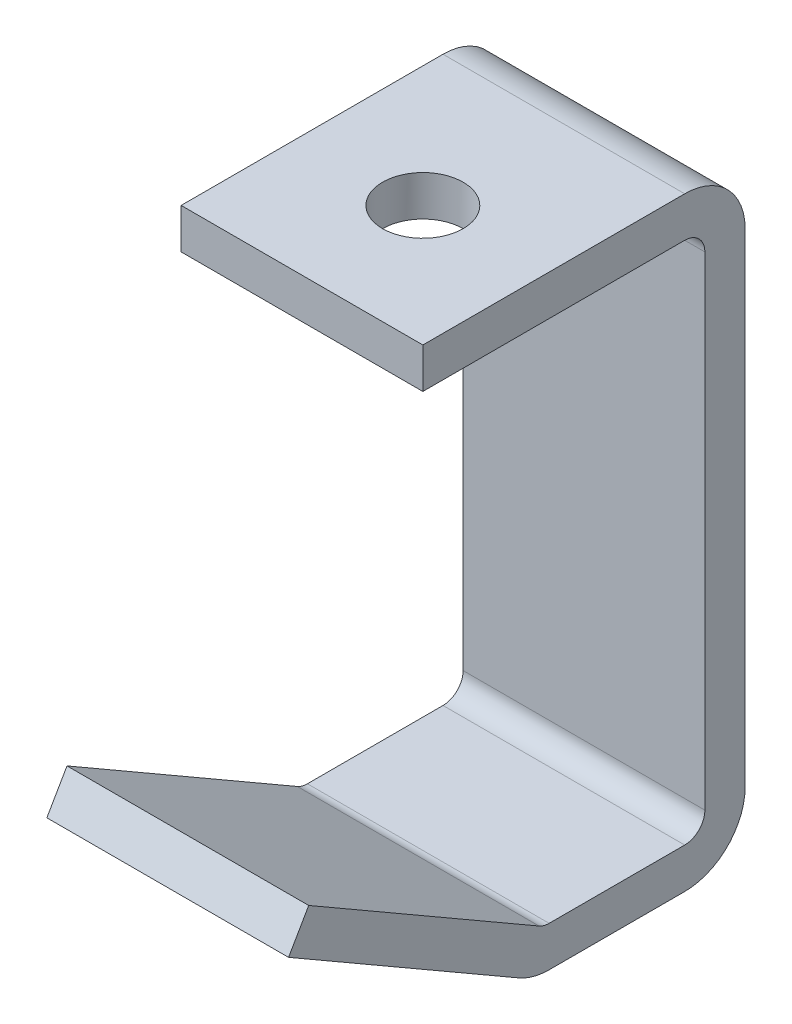
from build123d import *

# Parameters (mm, degrees)
BASE_EXTRUDE_THIN_DEPTH = 19.05
CUT_EXTRUDE1_REACH      = 97.25
SKETCH2_R               = 6.35


with BuildPart() as part:
    # Sketch1 → Base-Extrude-Thin (new body, symmetric)
    with BuildSketch(Plane(origin=(0, 0, 0), x_dir=(0, 0, -1), z_dir=(1, 0, 0))):
        with BuildLine():
            Line((-62.443024211, 21.3868), (-26.136761314, 0.425369343))
            ThreePointArc((-26.136761314, 0.425369343), (-25.371011782, 0.108185502), (-24.549261314, 0))
            Line((-24.549261314, 0), (-3.175, 0))
            ThreePointArc((-3.175, 0), (-0.92993597, 0.92993597), (0, 3.175))
            Line((0, 3.175), (0, 79.375))
            ThreePointArc((0, 79.375), (-0.92993597, 81.62006403), (-3.175, 82.55))
            Line((-3.175, 82.55), (-44.45, 82.55))
            Line((-44.45, 82.55), (-44.45, 88.9))
            Line((-44.45, 88.9), (-3.175, 88.9))
            ThreePointArc((-3.175, 88.9), (3.560192091, 86.110192091), (6.35, 79.375))
            Line((6.35, 79.375), (6.35, 3.175))
            ThreePointArc((6.35, 3.175), (3.560192091, -3.560192091), (-3.175, -6.35))
            Line((-3.175, -6.35), (-24.549261314, -6.35))
            ThreePointArc((-24.549261314, -6.35), (-27.014512719, -6.025443495), (-29.311761314, -5.073891971))
            Line((-29.311761314, -5.073891971), (-65.618024211, 15.887538686))
            Line((-65.618024211, 15.887538686), (-62.443024211, 21.3868))
        make_face()
    extrude(amount=BASE_EXTRUDE_THIN_DEPTH, both=True)

    # Sketch2 → Cut-Extrude1 (cut, up to next)
    with BuildSketch(Plane(origin=(0, 88.9, 0), x_dir=(-1, 0, 0), z_dir=(0, 1, 0)), mode=Mode.PRIVATE) as cut_extrude1_sk1:
        with Locations((0, 25.4)):
            Circle(SKETCH2_R)
    cut_extrude1_tool1 = extrude(cut_extrude1_sk1.sketch, amount=-CUT_EXTRUDE1_REACH, mode=Mode.PRIVATE) & part.part
    add(cut_extrude1_tool1.solids().sort_by_distance((0, 88.9, 25.4))[0], mode=Mode.SUBTRACT)


solid = part.part
